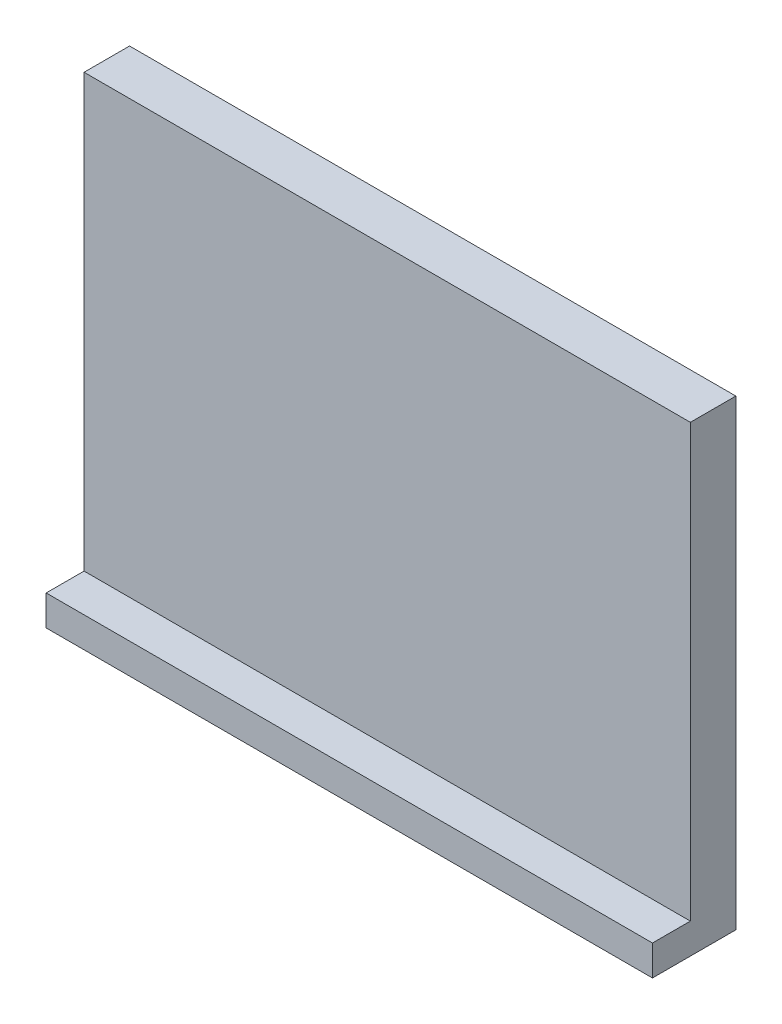
from build123d import *

# Parameters (mm, degrees)
CROQUIS1_W              = 80
CROQUIS1_H              = 61
SALIENTE_EXTRUIR1_DEPTH = 6
CROQUIS2_W              = 80
CROQUIS2_H              = 4
SALIENTE_EXTRUIR2_DEPTH = 5


with BuildPart() as part:
    # Croquis1 → Saliente-Extruir1 (new body)
    with BuildSketch(Plane.XY):
        with Locations((40, 30.5)):
            Rectangle(CROQUIS1_W, CROQUIS1_H)
    extrude(amount=SALIENTE_EXTRUIR1_DEPTH)

    # Croquis2 → Saliente-Extruir2 (add)
    with BuildSketch(Plane.XY.offset(6)):
        with Locations((40, 2)):
            Rectangle(CROQUIS2_W, CROQUIS2_H)
    extrude(amount=SALIENTE_EXTRUIR2_DEPTH)


solid = part.part
